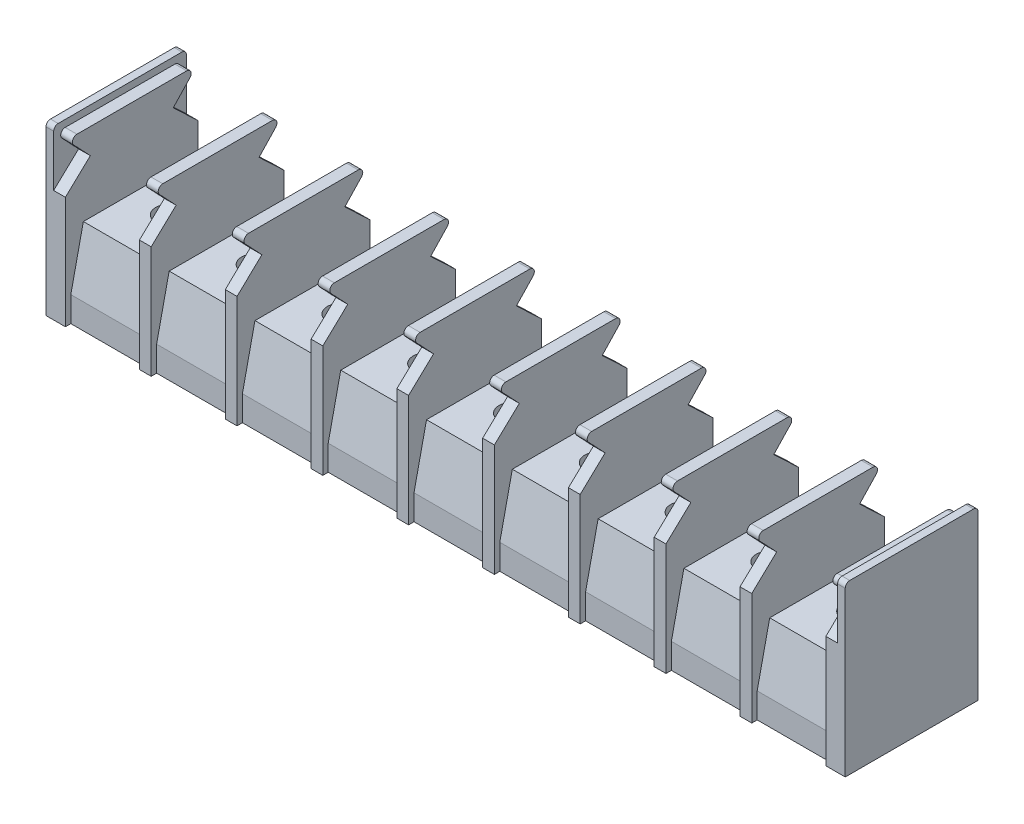
from build123d import *

# Parameters (mm, degrees)
BOSS_EXTRUDE1_DEPTH         = 44.25
BOSS_EXTRUDE2_DEPTH         = 0.85
BOSS_EXTRUDE3_DEPTH         = 1.3
LPATTERN1_COUNT             = 10
LPATTERN1_PITCH             = 9.5
M3_5X0_6_TAPPED_HOLE1_D     = 2.9
M3_5X0_6_TAPPED_HOLE1_DEPTH = 8
M3_5X0_6_TAPPED_HOLE1_TIP   = 0.871247898


with BuildPart() as part:
    # Sketch1 → Boss-Extrude1 (new body, symmetric)
    with BuildSketch(Plane(origin=(0, 0, 0), x_dir=(0, 0, -1), z_dir=(1, 0, 0))):
        Polygon((6.75, 0), (6.75, 2.79), (5.365, 9.1), (-5.365, 9.1), (-6.75, 2.79), (-6.75, 0), align=None)
    extrude(amount=BOSS_EXTRUDE1_DEPTH, both=True)

    # Sketch3 → Boss-Extrude2 (add)
    with BuildSketch(Plane(origin=(44.25, 0, 0), x_dir=(0, 0, -1), z_dir=(1, 0, 0))):
        with BuildLine():
            Line((-6.75, 0), (-7.35, 0))
            Line((-7.35, 0), (-7.35, 18.1))
            ThreePointArc((-7.35, 18.1), (-7.203553391, 18.453553391), (-6.85, 18.6))
            Line((-6.85, 18.6), (6.85, 18.6))
            ThreePointArc((6.85, 18.6), (7.203553391, 18.453553391), (7.35, 18.1))
            Line((7.35, 18.1), (7.35, 0))
            Line((7.35, 0), (6.75, 0))
            Line((6.75, 0), (6.75, 2.79))
            Line((6.75, 2.79), (5.365, 9.1))
            Line((5.365, 9.1), (-5.365, 9.1))
            Line((-5.365, 9.1), (-6.75, 2.79))
            Line((-6.75, 2.79), (-6.75, 0))
        make_face()
    boss_extrude2 = extrude(amount=-BOSS_EXTRUDE2_DEPTH)

    # Mirror1: Boss-Extrude2 across plane
    add(boss_extrude2.mirror(Plane(origin=(0, 0, 0), x_dir=(0, 0, 1), z_dir=(1, 0, 0))))

    # Sketch4 → Boss-Extrude3 (add)
    with BuildSketch(Plane.ZY.offset(-43.4)):
        with BuildLine():
            Line((7.35, 0), (7.35, 12.42))
            Line((7.35, 12.42), (4.588898397, 15.03))
            Line((4.588898397, 15.03), (6.438355915, 16.98652878))
            ThreePointArc((6.438355915, 16.98652878), (6.534203446, 17.527818591), (6.075, 17.83))
            Line((6.075, 17.83), (-6.075, 17.83))
            ThreePointArc((-6.075, 17.83), (-6.534203446, 17.527818591), (-6.438355915, 16.98652878))
            Line((-6.438355915, 16.98652878), (-4.588898397, 15.03))
            Line((-4.588898397, 15.03), (-7.35, 12.42))
            Line((-7.35, 12.42), (-7.35, 0))
            Line((-7.35, 0), (-6.75, 0))
            Line((-6.75, 0), (-6.75, 2.79))
            Line((-6.75, 2.79), (-5.365, 9.1))
            Line((-5.365, 9.1), (5.365, 9.1))
            Line((5.365, 9.1), (6.75, 2.79))
            Line((6.75, 2.79), (6.75, 0))
            Line((6.75, 0), (7.35, 0))
        make_face()
    boss_extrude3 = extrude(amount=BOSS_EXTRUDE3_DEPTH)

    # LPattern1: Boss-Extrude3 ×10
    with Locations(*[(-i * LPATTERN1_PITCH, 0, 0) for i in range(1, LPATTERN1_COUNT)]):
        add(boss_extrude3)

    # M3.5x0.6 Tapped Hole1
    with Locations(Plane(origin=(0, 9.1, 0), x_dir=(1, 0, 0), z_dir=(0, 1, 0))):
        with Locations((-38, 0), (-28.5, 0), (-19, 0), (-9.5, 0), (0, 0), (9.5, 0), (19, 0), (28.5, 0), (38, 0)):
            Hole(M3_5X0_6_TAPPED_HOLE1_D / 2, depth=M3_5X0_6_TAPPED_HOLE1_DEPTH)
            with Locations((0, 0, -(M3_5X0_6_TAPPED_HOLE1_DEPTH + M3_5X0_6_TAPPED_HOLE1_TIP / 2))):  # 118° drill point
                Cone(0, M3_5X0_6_TAPPED_HOLE1_D / 2, M3_5X0_6_TAPPED_HOLE1_TIP, mode=Mode.SUBTRACT)


solid = part.part
